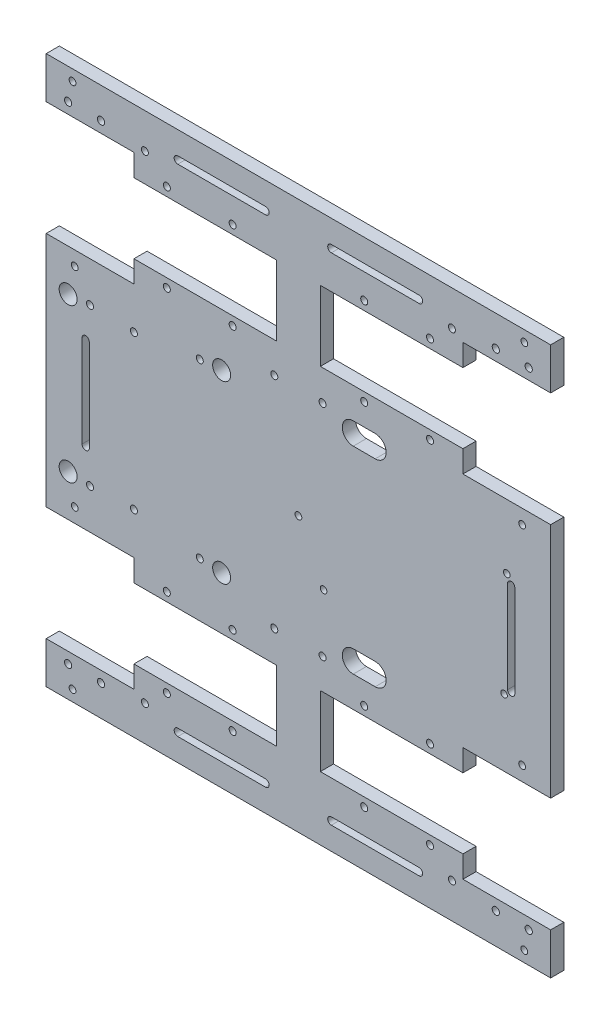
from build123d import *

# Parameters (mm, degrees)
ESBO_O1_W                   = 230
ESBO_O1_H                   = 250
RESSALTO_EXTRUS_O1_DEPTH    = 6
ESBO_O2_R                   = 1.6
MOTOR_DEPTH                 = 6
ESBO_O4_R                   = 4.1
ESBO_O4_R_2                 = 1.6
GARRA_DEPTH                 = 10
ESBO_O7_R                   = 1.65
SENSORES_FRONTAIS_DEPTH     = 10
ESBO_O5_R                   = 1.6
ESBO_O5_R_2                 = 1.55
MAOS_FRANCESAS_DEPTH        = 10
ESPELHAR2_COPY_1_SKETCH_R   = 1.6
ESPELHAR2_COPY_1_DEPTH      = 6
ESPELHAR2_COPY_2_SKETCH_R   = 1.65
ESPELHAR2_COPY_2_DEPTH      = 10
ESPELHAR2_COPY_3_SKETCH_R   = 1.6
ESPELHAR2_COPY_3_SKETCH_R_2 = 1.55
ESPELHAR2_COPY_3_DEPTH      = 10
SENSORES_LATERAIS_DEPTH     = 10
FIOS_DEPTH                  = 10
ESBO_O10_R                  = 1.5
CORTE_EXTRUS_O7_DEPTH       = 10


with BuildPart() as part:
    # Esboço1 → Ressalto-extrusão1 (new body)
    with BuildSketch(Plane.XY):
        Rectangle(ESBO_O1_W, ESBO_O1_H)
    extrude(amount=RESSALTO_EXTRUS_O1_DEPTH)

    # Esboço2 → motor (cut)
    with BuildSketch(Plane.XY.offset(6)):
        with Locations((-60, 100)):
            Circle(ESBO_O2_R)
        with Locations((-30, 100)):
            Circle(ESBO_O2_R)
        with Locations((-30, 60)):
            Circle(ESBO_O2_R)
        with Locations((-60, 60)):
            Circle(ESBO_O2_R)
        Polygon((-75, 64), (-75, 54), (-115, 54), (-115, 106), (-75, 106), (-75, 96), (-10, 96), (-10, 64), align=None)
    motor = extrude(amount=-MOTOR_DEPTH, mode=Mode.SUBTRACT)

    # Esboço4 → garra (cut)
    with BuildSketch(Plane.XY.offset(6)):
        with Locations((-105, 35)):
            Circle(ESBO_O4_R)
        with Locations((-44.974586998, 39.2875295)):
            Circle(ESBO_O4_R_2)
        with Locations((-95.025413002, 35.7124705)):
            Circle(ESBO_O4_R_2)
        with Locations((-35, 40)):
            Circle(ESBO_O4_R)
        with Locations((-44.974586998, -39.2875295)):
            Circle(ESBO_O4_R_2)
        with Locations((-35, -40)):
            Circle(ESBO_O4_R)
        with Locations((-95.025413002, -35.7124705)):
            Circle(ESBO_O4_R_2)
        with Locations((-105, -35)):
            Circle(ESBO_O4_R)
        with Locations((-75, 35)):
            Circle(ESBO_O4_R_2)
        with Locations((-75, -35)):
            Circle(ESBO_O4_R_2)
    extrude(amount=-GARRA_DEPTH, mode=Mode.SUBTRACT)

    # Esboço7 → sensores frontais (cut)
    with BuildSketch(Plane.XY.offset(6)):
        with Locations((-105, 111)):
            Circle(ESBO_O7_R)
        with Locations((-90, 111)):
            Circle(ESBO_O7_R)
        with BuildLine():
            Line((-15, 111.35), (-55, 111.35))
            ThreePointArc((-55, 111.35), (-56.65, 113), (-55, 114.65))
            Line((-55, 114.65), (-15, 114.65))
            ThreePointArc((-15, 114.65), (-13.35, 113), (-15, 111.35))
        make_face()
    sensores_frontais = extrude(amount=-SENSORES_FRONTAIS_DEPTH, mode=Mode.SUBTRACT)

    # Esboço5 → maos francesas (cut)
    with BuildSketch(Plane(origin=(0, 0, 0), x_dir=(-1, 0, 0), z_dir=(0, 0, -1))):
        with Locations((70, 109)):
            Circle(ESBO_O5_R)
        with Locations((-102, 47.5)):
            Circle(ESBO_O5_R_2)
        with Locations((-103, 120)):
            Circle(ESBO_O5_R_2)
        with Locations((11, 50)):
            Circle(ESBO_O5_R)
        Circle(ESBO_O5_R_2)
        with Locations((-11, 50)):
            Circle(ESBO_O5_R)
        with Locations((-11, -50)):
            Circle(ESBO_O5_R)
        with Locations((11, -50)):
            Circle(ESBO_O5_R)
    maos_francesas = extrude(amount=-MAOS_FRANCESAS_DEPTH, mode=Mode.SUBTRACT)

    # Espelhar1: motor, sensores frontais, maos francesas across plane
    add(motor.mirror(Plane(origin=(0, 0, 0), x_dir=(0, 0, 1), z_dir=(1, 0, 0))), mode=Mode.SUBTRACT)
    add(sensores_frontais.mirror(Plane(origin=(0, 0, 0), x_dir=(0, 0, 1), z_dir=(1, 0, 0))), mode=Mode.SUBTRACT)
    add(maos_francesas.mirror(Plane(origin=(0, 0, 0), x_dir=(0, 0, 1), z_dir=(1, 0, 0))), mode=Mode.SUBTRACT)

    # Espelhar2: motor, sensores frontais, maos francesas across plane
    add(motor.mirror(Plane.ZX), mode=Mode.SUBTRACT)
    add(sensores_frontais.mirror(Plane.ZX), mode=Mode.SUBTRACT)
    add(maos_francesas.mirror(Plane.ZX), mode=Mode.SUBTRACT)

    # Espelhar2 copy 1 sketch → Espelhar2 copy 1 (cut)
    with BuildSketch(Plane(origin=(0, 0, 6), x_dir=(-1, 0, 0), z_dir=(0, 0, 1))):
        with Locations((-60, 100)):
            Circle(ESPELHAR2_COPY_1_SKETCH_R)
        with Locations((-30, 100)):
            Circle(ESPELHAR2_COPY_1_SKETCH_R)
        with Locations((-30, 60)):
            Circle(ESPELHAR2_COPY_1_SKETCH_R)
        with Locations((-60, 60)):
            Circle(ESPELHAR2_COPY_1_SKETCH_R)
        Polygon((-75, 64), (-75, 54), (-115, 54), (-115, 106), (-75, 106), (-75, 96), (-10, 96), (-10, 64), align=None)
    extrude(amount=-ESPELHAR2_COPY_1_DEPTH, mode=Mode.SUBTRACT)

    # Espelhar2 copy 2 sketch → Espelhar2 copy 2 (cut)
    with BuildSketch(Plane(origin=(0, 0, 6), x_dir=(-1, 0, 0), z_dir=(0, 0, 1))):
        with Locations((-105, 111)):
            Circle(ESPELHAR2_COPY_2_SKETCH_R)
        with Locations((-90, 111)):
            Circle(ESPELHAR2_COPY_2_SKETCH_R)
        with BuildLine():
            Line((-15, 111.35), (-55, 111.35))
            ThreePointArc((-55, 111.35), (-56.65, 113), (-55, 114.65))
            Line((-55, 114.65), (-15, 114.65))
            ThreePointArc((-15, 114.65), (-13.35, 113), (-15, 111.35))
        make_face()
    extrude(amount=-ESPELHAR2_COPY_2_DEPTH, mode=Mode.SUBTRACT)

    # Espelhar2 copy 3 sketch → Espelhar2 copy 3 (cut)
    with BuildSketch(Plane(origin=(0, 0, 0), x_dir=(1, 0, 0), z_dir=(0, 0, -1))):
        with Locations((70, 109)):
            Circle(ESPELHAR2_COPY_3_SKETCH_R)
        with Locations((-102, 47.5)):
            Circle(ESPELHAR2_COPY_3_SKETCH_R_2)
        with Locations((-103, 120)):
            Circle(ESPELHAR2_COPY_3_SKETCH_R_2)
        with Locations((11, 50)):
            Circle(ESPELHAR2_COPY_3_SKETCH_R)
        Circle(ESPELHAR2_COPY_3_SKETCH_R_2)
        with Locations((-11, 50)):
            Circle(ESPELHAR2_COPY_3_SKETCH_R)
        with Locations((-11, -50)):
            Circle(ESPELHAR2_COPY_3_SKETCH_R)
        with Locations((11, -50)):
            Circle(ESPELHAR2_COPY_3_SKETCH_R)
    extrude(amount=-ESPELHAR2_COPY_3_DEPTH, mode=Mode.SUBTRACT)

    # Esboço8 → Sensores laterais (cut)
    with BuildSketch(Plane.XY.offset(6)):
        with BuildLine():
            Line((-98.65, -21), (-98.65, 21))
            ThreePointArc((-98.65, 21), (-97, 22.65), (-95.35, 21))
            Line((-95.35, 21), (-95.35, -21))
            ThreePointArc((-95.35, -21), (-97, -22.65), (-98.65, -21))
        make_face()
        with BuildLine():
            Line((98.65, -21), (98.65, 21))
            ThreePointArc((98.65, 21), (97, 22.65), (95.35, 21))
            Line((95.35, 21), (95.35, -21))
            ThreePointArc((95.35, -21), (97, -22.65), (98.65, -21))
        make_face()
    extrude(amount=-SENSORES_LATERAIS_DEPTH, mode=Mode.SUBTRACT)

    # Esboço9 → Fios (cut)
    with BuildSketch(Plane(origin=(0, 0, 0), x_dir=(-1, 0, 0), z_dir=(0, 0, -1))):
        with BuildLine():
            Line((-35, 50), (-25, 50))
            ThreePointArc((-25, 50), (-20, 45), (-25, 40))
            Line((-25, 40), (-35, 40))
            ThreePointArc((-35, 40), (-40, 45), (-35, 50))
        make_face()
        with BuildLine():
            Line((-35, -50), (-25, -50))
            ThreePointArc((-25, -50), (-20, -45), (-25, -40))
            Line((-25, -40), (-35, -40))
            ThreePointArc((-35, -40), (-40, -45), (-35, -50))
        make_face()
    extrude(amount=-FIOS_DEPTH, mode=Mode.SUBTRACT)

    # Esboço10 → Corte-extrusão7 (cut)
    with BuildSketch(Plane(origin=(0, 0, 0), x_dir=(-1, 0, 0), z_dir=(0, 0, -1))):
        with Locations((-95, 24.686677652)):
            Circle(ESBO_O10_R)
        with Locations((-93.76, -23.483322348)):
            Circle(ESBO_O10_R)
        with Locations((-11.46, -23.483322348)):
            Circle(ESBO_O10_R)
    extrude(amount=-CORTE_EXTRUS_O7_DEPTH, mode=Mode.SUBTRACT)


solid = part.part
